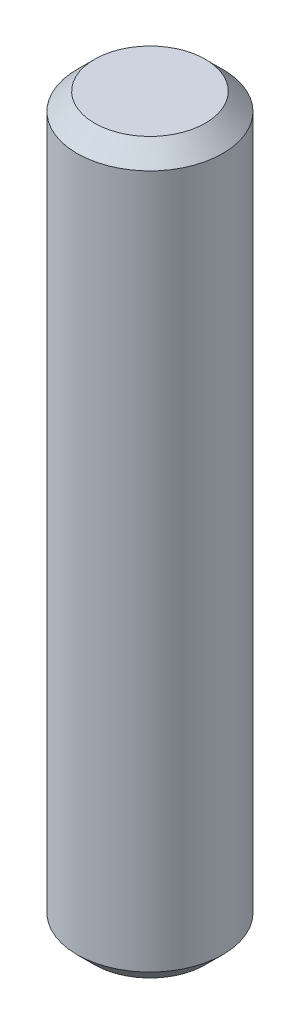
from build123d import *

# Parameters (mm, degrees)
SKETCH1_R           = 6.35
BOSS_EXTRUDE1_DEPTH = 31.75
CHAMFER1_SIZE       = 1.524


with BuildPart() as part:
    # Sketch1 → Boss-Extrude1 (new body, symmetric)
    with BuildSketch(Plane(origin=(0, 0, 0), x_dir=(1, 0, 0), z_dir=(0, 1, 0))):
        Circle(SKETCH1_R)
    extrude(amount=BOSS_EXTRUDE1_DEPTH, both=True)

    # Chamfer1
    chamfer1_edges = [part.edges().sort_by_distance(p)[0] for p in [
        (-6.35, -31.75, 0),
        (-6.35, 31.75, 0),
    ]]
    chamfer(chamfer1_edges, length=CHAMFER1_SIZE)


solid = part.part
